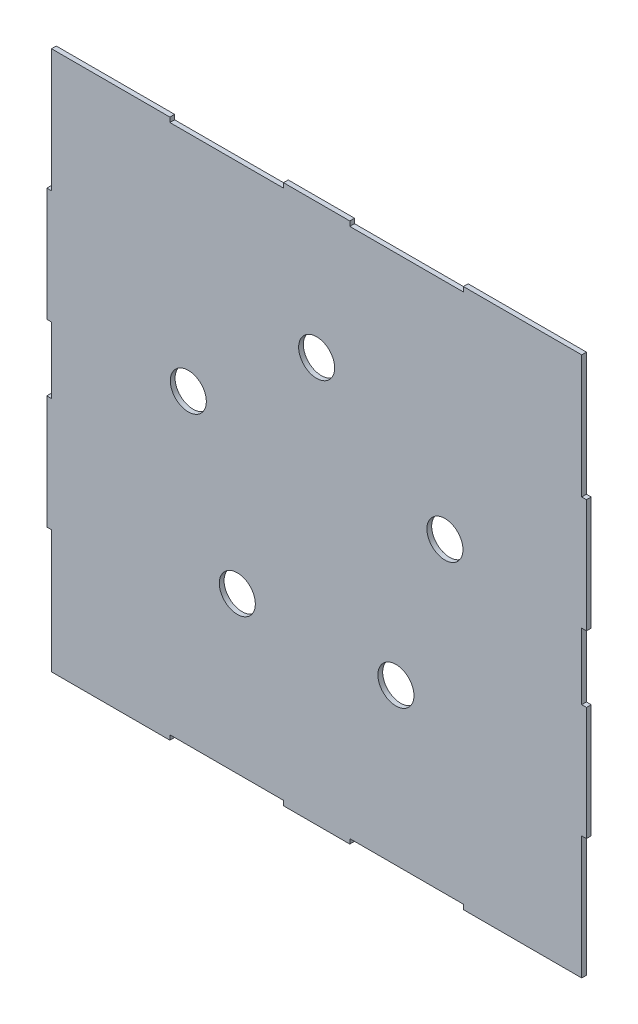
from build123d import *

# Parameters (mm, degrees)
SKETCH1_W           = 361.95
SKETCH1_H           = 361.95
BOSS_EXTRUDE1_DEPTH = 3.175
SKETCH2_W           = 76.2
SKETCH2_H           = 3.175
CUT_EXTRUDE1_DEPTH  = 3.175
SKETCH3_R           = 12.0777
SKETCH3_W           = 3.175
SKETCH3_H           = 82.55
SKETCH3_H_2         = 44.45
CUT_EXTRUDE2_DEPTH  = 3.175


with BuildPart() as part:
    # Sketch1 → Boss-Extrude1 (new body)
    with BuildSketch(Plane.XY):
        Rectangle(SKETCH1_W, SKETCH1_H)
    extrude(amount=BOSS_EXTRUDE1_DEPTH)

    # Sketch2 → Cut-Extrude1 (cut)
    with BuildSketch(Plane.XY.offset(3.175)):
        with Locations((-60.325, 179.3875)):
            Rectangle(SKETCH2_W, SKETCH2_H)
        with Locations((60.325, 179.3875)):
            Rectangle(SKETCH2_W, SKETCH2_H)
        with Locations((60.325, -179.3875)):
            Rectangle(SKETCH2_W, SKETCH2_H)
        with Locations((-60.325, -179.3875)):
            Rectangle(SKETCH2_W, SKETCH2_H)
    extrude(amount=-CUT_EXTRUDE1_DEPTH, mode=Mode.SUBTRACT)

    # Sketch3 → Cut-Extrude2 (cut)
    with BuildSketch(Plane.XY.offset(3.175)):
        with Locations((0, 90.4875)):
            Circle(SKETCH3_R)
        with Locations((86.058726518, 27.962175279)):
            Circle(SKETCH3_R)
        with Locations((53.187218017, -73.205925279)):
            Circle(SKETCH3_R)
        with Locations((-53.187218017, -73.205925279)):
            Circle(SKETCH3_R)
        with Locations((-86.058726518, 27.962175279)):
            Circle(SKETCH3_R)
        with Locations((-179.3875, 139.7)):
            Rectangle(SKETCH3_W, SKETCH3_H)
        with Locations((-179.3875, 0)):
            Rectangle(SKETCH3_W, SKETCH3_H_2)
        with Locations((-179.3875, -139.7)):
            Rectangle(SKETCH3_W, SKETCH3_H)
        with Locations((179.3875, -139.7)):
            Rectangle(SKETCH3_W, SKETCH3_H)
        with Locations((179.3875, 0)):
            Rectangle(SKETCH3_W, SKETCH3_H_2)
        with Locations((179.3875, 139.7)):
            Rectangle(SKETCH3_W, SKETCH3_H)
    extrude(amount=-CUT_EXTRUDE2_DEPTH, mode=Mode.SUBTRACT)


solid = part.part
